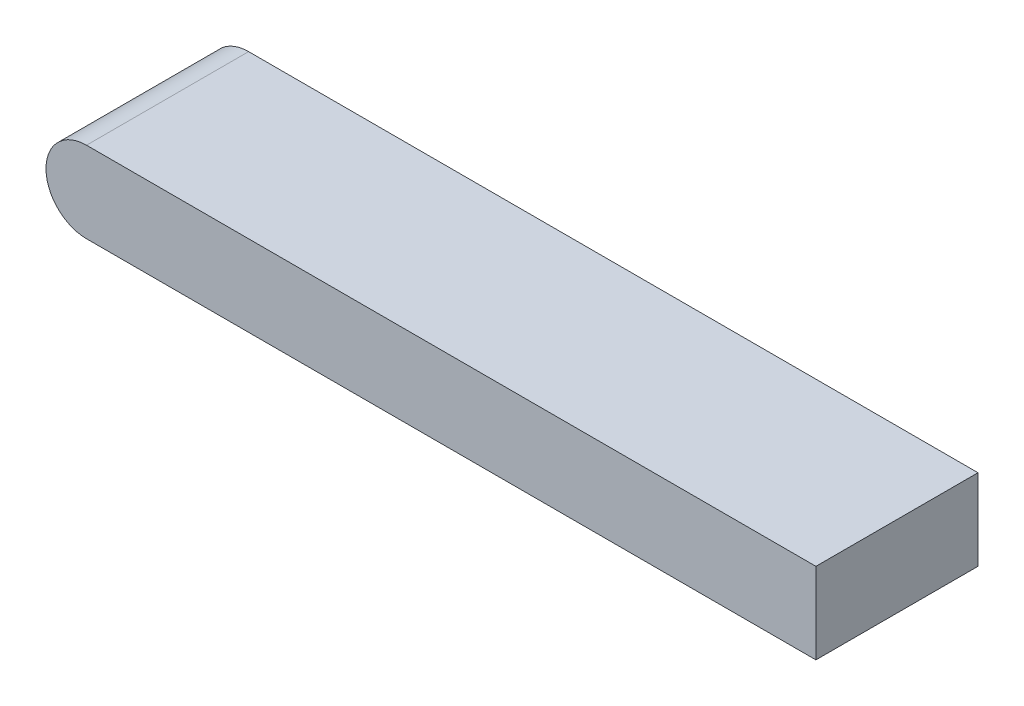
from build123d import *

# Parameters (mm, degrees)
SKETCH_1_W      = 36
SKETCH_1_H      = 8
EXTRUDE_1_DEPTH = 4
SKETCH_2_R      = 2
EXTRUDE_2_DEPTH = 8


with BuildPart() as part:
    # 草图1 → 凸台-拉伸1 (new body)
    with BuildSketch(Plane(origin=(0, 0, 0), x_dir=(1, 0, 0), z_dir=(0, 1, 0))):
        with Locations((-8, 0)):
            Rectangle(SKETCH_1_W, SKETCH_1_H)
    extrude(amount=EXTRUDE_1_DEPTH)

    # 草图2 → 凸台-拉伸2 (add)
    with BuildSketch(Plane.XY.offset(4)):
        with Locations((-26, 2)):
            Circle(SKETCH_2_R)
    extrude(amount=-EXTRUDE_2_DEPTH)


solid = part.part
